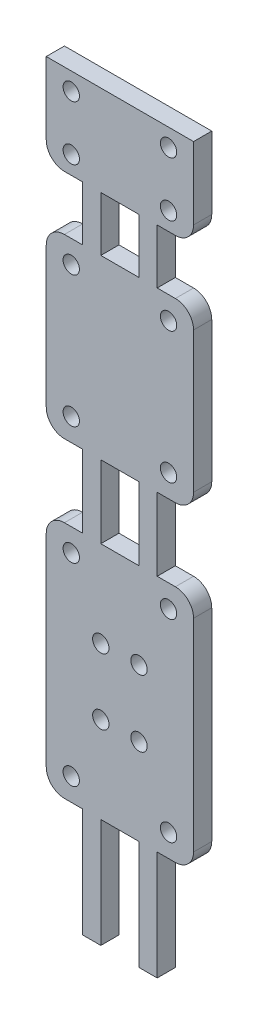
from build123d import *

# Parameters (mm, degrees)
SKETCH3_R           = 0.9
SKETCH3_W           = 4.2
SKETCH3_H           = 8
SKETCH3_H_2         = 6
BOSS_EXTRUDE3_DEPTH = 2


with BuildPart() as part:
    # Sketch3 → Boss-Extrude3 (new body)
    with BuildSketch(Plane.XY):
        with BuildLine():
            Line((0, 94.006448831), (0, 86.061448831))
            ThreePointArc((0, 86.061448831), (0.585786438, 84.647235269), (2, 84.061448831))
            Line((2, 84.061448831), (4, 84.061448831))
            Line((4, 84.061448831), (4, 78.061448831))
            Line((4, 78.061448831), (2, 78.061448831))
            ThreePointArc((2, 78.061448831), (0.585786438, 77.475662393), (0, 76.061448831))
            Line((0, 76.061448831), (0, 60.606448831))
            ThreePointArc((0, 60.606448831), (0.585786438, 59.192235269), (2, 58.606448831))
            Line((2, 58.606448831), (4, 58.606448831))
            Line((4, 58.606448831), (4, 50.606448831))
            Line((4, 50.606448831), (2, 50.606448831))
            ThreePointArc((2, 50.606448831), (0.585786438, 50.020662393), (0, 48.606448831))
            Line((0, 48.606448831), (0, 26.346448831))
            ThreePointArc((0, 26.346448831), (0.585786438, 24.932235269), (2, 24.346448831))
            Line((2, 24.346448831), (4, 24.346448831))
            Line((4, 24.346448831), (4, 12.346448831))
            Line((4, 12.346448831), (6, 12.346448831))
            Line((6, 12.346448831), (6, 24.346448831))
            Line((6, 24.346448831), (10.2, 24.346448831))
            Line((10.2, 24.346448831), (10.2, 12.346448831))
            Line((10.2, 12.346448831), (12.2, 12.346448831))
            Line((12.2, 12.346448831), (12.2, 24.346448831))
            Line((12.2, 24.346448831), (14.2, 24.346448831))
            ThreePointArc((14.2, 24.346448831), (15.614213562, 24.932235269), (16.2, 26.346448831))
            Line((16.2, 26.346448831), (16.2, 48.606448831))
            ThreePointArc((16.2, 48.606448831), (15.614213562, 50.020662393), (14.2, 50.606448831))
            Line((14.2, 50.606448831), (12.2, 50.606448831))
            Line((12.2, 50.606448831), (12.2, 58.606448831))
            Line((12.2, 58.606448831), (14.2, 58.606448831))
            ThreePointArc((14.2, 58.606448831), (15.614213562, 59.192235269), (16.2, 60.606448831))
            Line((16.2, 60.606448831), (16.2, 76.061448831))
            ThreePointArc((16.2, 76.061448831), (15.614213562, 77.475662393), (14.2, 78.061448831))
            Line((14.2, 78.061448831), (12.2, 78.061448831))
            Line((12.2, 78.061448831), (12.2, 84.061448831))
            Line((12.2, 84.061448831), (14.2, 84.061448831))
            ThreePointArc((14.2, 84.061448831), (15.614213562, 84.647235269), (16.2, 86.061448831))
            Line((16.2, 86.061448831), (16.2, 94.006448831))
            Line((16.2, 94.006448831), (0, 94.006448831))
        make_face()
        with Locations((6, 33.846448831)):
            Circle(SKETCH3_R, mode=Mode.SUBTRACT)
        with Locations((10.2, 33.846448831)):
            Circle(SKETCH3_R, mode=Mode.SUBTRACT)
        with Locations((2.75, 86.061448831)):
            Circle(SKETCH3_R, mode=Mode.SUBTRACT)
        with Locations((10.2, 41.166448831)):
            Circle(SKETCH3_R, mode=Mode.SUBTRACT)
        with Locations((13.45, 48.106448831)):
            Circle(SKETCH3_R, mode=Mode.SUBTRACT)
        with Locations((2.75, 92.061448831)):
            Circle(SKETCH3_R, mode=Mode.SUBTRACT)
        with Locations((13.45, 86.061448831)):
            Circle(SKETCH3_R, mode=Mode.SUBTRACT)
        with Locations((2.75, 61.106448831)):
            Circle(SKETCH3_R, mode=Mode.SUBTRACT)
        with Locations((13.45, 61.106448831)):
            Circle(SKETCH3_R, mode=Mode.SUBTRACT)
        with Locations((2.75, 75.561448831)):
            Circle(SKETCH3_R, mode=Mode.SUBTRACT)
        with Locations((13.45, 26.846448831)):
            Circle(SKETCH3_R, mode=Mode.SUBTRACT)
        with Locations((13.45, 75.561448831)):
            Circle(SKETCH3_R, mode=Mode.SUBTRACT)
        with Locations((13.45, 92.061448831)):
            Circle(SKETCH3_R, mode=Mode.SUBTRACT)
        with Locations((2.75, 26.846448831)):
            Circle(SKETCH3_R, mode=Mode.SUBTRACT)
        with Locations((6, 41.106448831)):
            Circle(SKETCH3_R, mode=Mode.SUBTRACT)
        with Locations((2.75, 48.106448831)):
            Circle(SKETCH3_R, mode=Mode.SUBTRACT)
        with Locations((8.1, 54.606448831)):
            Rectangle(SKETCH3_W, SKETCH3_H, mode=Mode.SUBTRACT)
        with Locations((8.1, 81.061448831)):
            Rectangle(SKETCH3_W, SKETCH3_H_2, mode=Mode.SUBTRACT)
    extrude(amount=BOSS_EXTRUDE3_DEPTH)


solid = part.part
